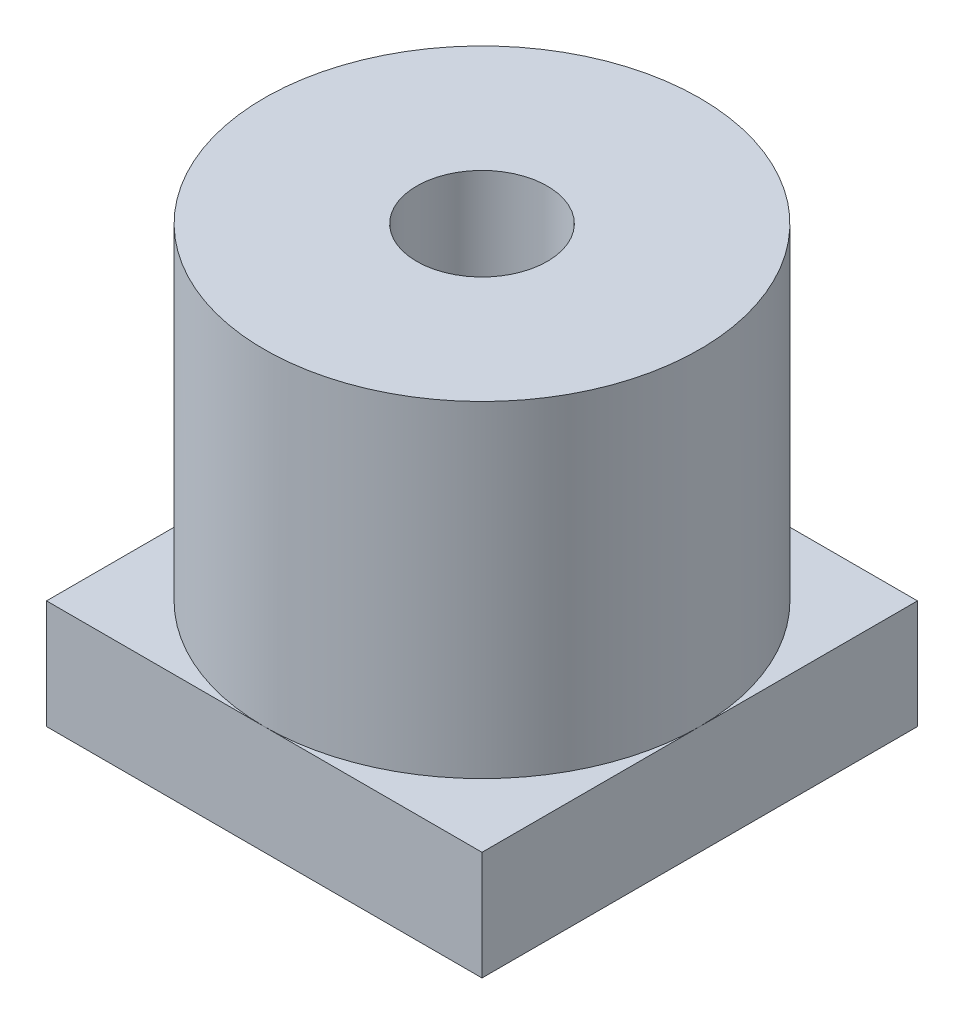
from build123d import *

# Parameters (mm, degrees)
SKETCH1_W           = 20
SKETCH1_H           = 20
BOSS_EXTRUDE1_DEPTH = 20
SKETCH2_OUTSIDE_W   = 28.928
SKETCH2_OUTSIDE_H   = 28.928
SKETCH2_OUTSIDE_R   = 10
CUT_EXTRUDE1_DEPTH  = 15
SKETCH3_R           = 3
CUT_EXTRUDE2_DEPTH  = 21


with BuildPart() as part:
    # Sketch1 → Boss-Extrude1 (new body)
    with BuildSketch(Plane(origin=(0, 0, 0), x_dir=(1, 0, 0), z_dir=(0, 1, 0))):
        with Locations((10, 10)):
            Rectangle(SKETCH1_W, SKETCH1_H)
    extrude(amount=BOSS_EXTRUDE1_DEPTH)

    # Sketch2 outside → Cut-Extrude1 (cut)
    with BuildSketch(Plane(origin=(0, 20, 0), x_dir=(1, 0, 0), z_dir=(0, 1, 0))):
        with Locations((10, 10)):
            Rectangle(SKETCH2_OUTSIDE_W, SKETCH2_OUTSIDE_H)
        with Locations((10, 10)):
            Circle(SKETCH2_OUTSIDE_R, mode=Mode.SUBTRACT)
    extrude(amount=-CUT_EXTRUDE1_DEPTH, mode=Mode.SUBTRACT)

    # Sketch3 → Cut-Extrude2 (cut, through all)
    with BuildSketch(Plane(origin=(0, 20, 0), x_dir=(1, 0, 0), z_dir=(0, 1, 0))):
        with Locations((10, 10)):
            Circle(SKETCH3_R)
    extrude(amount=-CUT_EXTRUDE2_DEPTH, mode=Mode.SUBTRACT)


solid = part.part
